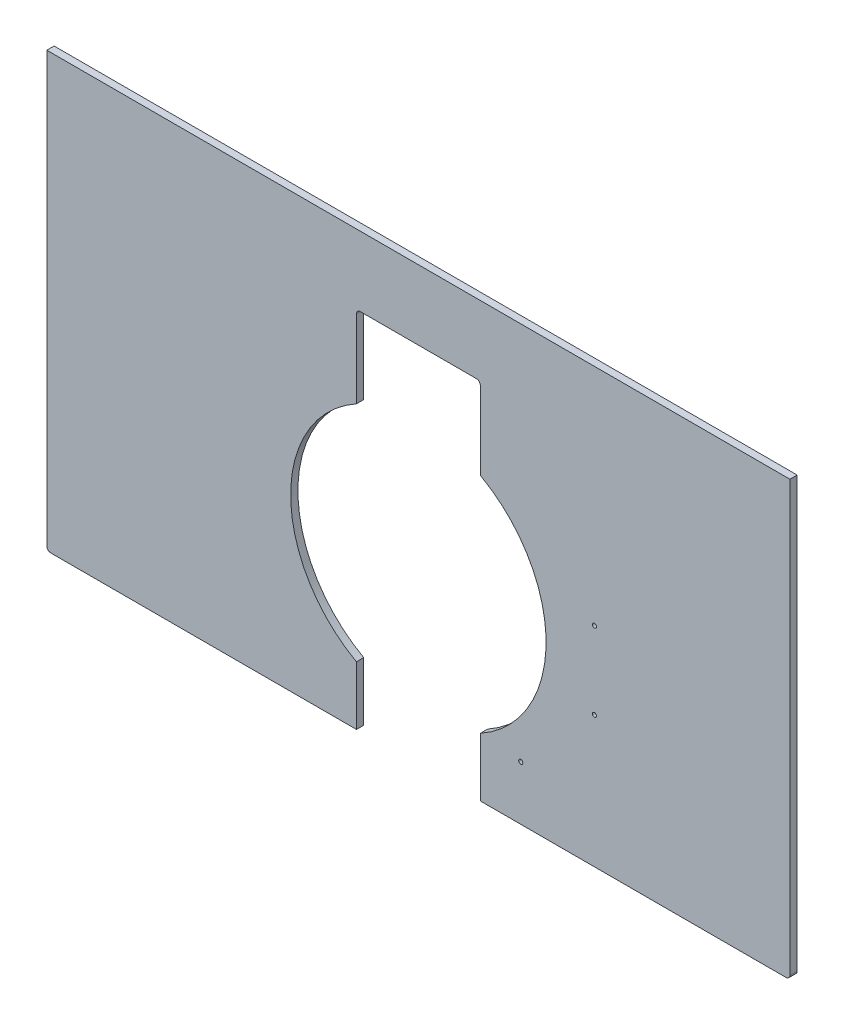
from build123d import *

# Parameters (mm, degrees)
SKETCH1_W           = 1219.2
SKETCH1_H           = 1778
SKETCH1_R           = 254
SKETCH1_W_2         = 361.95
SKETCH1_H_2         = 361.95
BOSS_EXTRUDE1_DEPTH = 11.90625
SKETCH3_R           = 209.55
CUT_EXTRUDE2_DEPTH  = 12.90625
SKETCH2_W           = 203.2
SKETCH2_H           = 165.1
CUT_EXTRUDE1_DEPTH  = 12.90625
SKETCH5_R           = 3.429
CUT_EXTRUDE4_DEPTH  = 12.90625
LPATTERN2_COUNT     = 3
LPATTERN2_PITCH     = 301.625
SKETCH7_R           = 3.3782
CUT_EXTRUDE6_DEPTH  = 12.90625
SKETCH12_R          = 4.7625
CUT_EXTRUDE7_DEPTH  = 12.90625
SKETCH16_R          = 4.7625
CUT_EXTRUDE10_DEPTH = 12.90625
FILLET2_R           = 6.35
SKETCH19_W          = 1219.2
SKETCH19_H          = 1066.8
CUT_EXTRUDE13_DEPTH = 12.7


with BuildPart() as part:
    # Sketch1 → Boss-Extrude1 (new body)
    with BuildSketch(Plane.XY):
        with Locations((609.6, 889)):
            Rectangle(SKETCH1_W, SKETCH1_H)
        with Locations((330.2, 1473.2)):
            Circle(SKETCH1_R, mode=Mode.SUBTRACT)
        with Locations((609.6, 917.575)):
            Rectangle(SKETCH1_W_2, SKETCH1_H_2, mode=Mode.SUBTRACT)
    extrude(amount=BOSS_EXTRUDE1_DEPTH)

    # Sketch3 → Cut-Extrude2 (cut, through all)
    with BuildSketch(Plane.XY.offset(11.90625)):
        with Locations((609.6, 279.4)):
            Circle(SKETCH3_R)
    extrude(amount=-CUT_EXTRUDE2_DEPTH, mode=Mode.SUBTRACT)

    # Sketch2 → Cut-Extrude1 (cut, through all)
    with BuildSketch(Plane.XY.offset(11.90625)):
        with Locations((609.6, 44.45)):
            Rectangle(SKETCH2_W, SKETCH2_H)
        with Locations((609.6, 514.35)):
            Rectangle(SKETCH2_W, SKETCH2_H)
    extrude(amount=-CUT_EXTRUDE1_DEPTH, mode=Mode.SUBTRACT)

    # Sketch5 → Cut-Extrude4 (cut, through all)
    with BuildSketch(Plane.XY.offset(11.90625)):
        with Locations((609.6, 1714.5)):
            Circle(SKETCH5_R)
    cut_extrude4 = extrude(amount=-CUT_EXTRUDE4_DEPTH, mode=Mode.SUBTRACT)

    # LPattern2: Cut-Extrude4 ×3
    with Locations(*[(0, -i * LPATTERN2_PITCH, 0) for i in range(1, LPATTERN2_COUNT)]):
        add(cut_extrude4, mode=Mode.SUBTRACT)

    # Sketch7 → Cut-Extrude6 (cut, through all)
    with BuildSketch(Plane.XY.offset(11.90625)):
        with Locations((777.605208253, 88.9)):
            Circle(SKETCH7_R)
        with Locations((898.525, 342.9)):
            Circle(SKETCH7_R)
        with Locations((898.525, 215.9)):
            Circle(SKETCH7_R)
    extrude(amount=-CUT_EXTRUDE6_DEPTH, mode=Mode.SUBTRACT)

    # Sketch12 → Cut-Extrude7 (cut, through all)
    with BuildSketch(Plane.XY.offset(11.90625)):
        with Locations((203.2, 1727.2)):
            Circle(SKETCH12_R)
        with Locations((1016, 1727.2)):
            Circle(SKETCH12_R)
    extrude(amount=-CUT_EXTRUDE7_DEPTH, mode=Mode.SUBTRACT)

    # Sketch16 → Cut-Extrude10 (cut, through all)
    with BuildSketch(Plane.XY.offset(11.90625)):
        with Locations((419.1, 1054.1)):
            Circle(SKETCH16_R)
        with Locations((419.1, 787.4)):
            Circle(SKETCH16_R)
        with Locations((800.1, 1054.1)):
            Circle(SKETCH16_R)
        with Locations((800.1, 787.4)):
            Circle(SKETCH16_R)
    extrude(amount=-CUT_EXTRUDE10_DEPTH, mode=Mode.SUBTRACT)

    # Fillet2
    fillet2_edges = [part.edges().sort_by_distance(p)[0] for p in [
        (428.625, 1098.55, 5.953125),
        (428.625, 736.6, 5.953125),
        (790.575, 736.6, 5.953125),
        (790.575, 1098.55, 5.953125),
        (711.2, 596.9, 5.953125),
        (508, 596.9, 5.953125),
        (0, 0, 5.953125),
        (1219.2, 0, 5.953125),
    ]]
    fillet(fillet2_edges, radius=FILLET2_R)

    # Sketch19 → Cut-Extrude13 (cut)
    with BuildSketch(Plane.XY.offset(11.90625)):
        with Locations((609.6, 1244.6)):
            Rectangle(SKETCH19_W, SKETCH19_H)
    extrude(amount=-CUT_EXTRUDE13_DEPTH, mode=Mode.SUBTRACT)


solid = part.part
